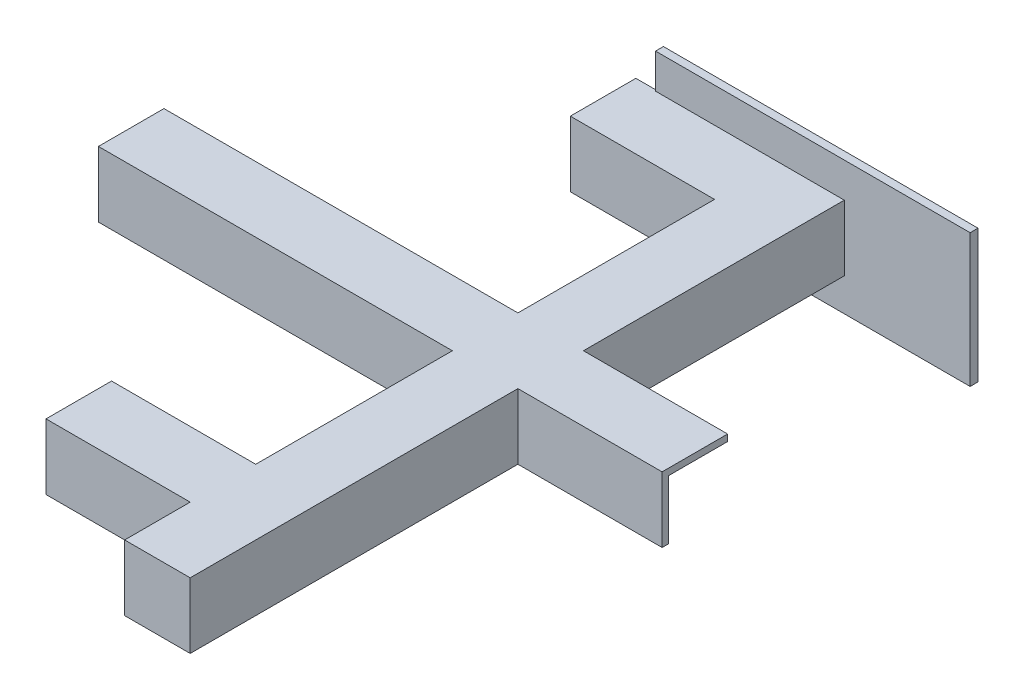
from build123d import *

# Parameters (mm, degrees)
BOSS_EXTRUDE1_START = 5
SKETCH1_W           = 50
SKETCH1_H           = 50
BOSS_EXTRUDE1_DEPTH = 500
BOSS_EXTRUDE2_DEPTH = 110
BOSS_EXTRUDE3_DEPTH = 110
BOSS_EXTRUDE5_START = 110
BOSS_EXTRUDE5_DEPTH = 160
SKETCH1_3_W         = 240
SKETCH1_3_H         = 101.6
SKETCH1_3_W_2       = 50
SKETCH1_3_H_2       = 50
BOSS_EXTRUDE6_DEPTH = 6


with BuildPart() as part:
    # Sketch1 → Boss-Extrude1 (new body)
    with BuildSketch(Plane.XY.offset(40212.600196057).offset(BOSS_EXTRUDE1_START)):
        with Locations((-21671.561141737, -1732.035725356)):
            Rectangle(SKETCH1_W, SKETCH1_H)
    extrude(amount=BOSS_EXTRUDE1_DEPTH)

    # Sketch2 → Boss-Extrude2 (add)
    with BuildSketch(Plane(origin=(-21646.561141737, 0, 0), x_dir=(0, 0, -1), z_dir=(1, 0, 0))):
        Polygon((-40467.600196057, -1707.035725356), (-40467.600196057, -1757.035725356), (-40462.600196057, -1757.035725356), (-40462.600196057, -1712.035725356), (-40417.600196057, -1712.035725356), (-40417.600196057, -1707.035725356), align=None)
    extrude(amount=BOSS_EXTRUDE2_DEPTH)

    # Sketch3 → Boss-Extrude3 (add)
    with BuildSketch(Plane.ZY.offset(21696.561141737)):
        Polygon((40667.600196057, -1707.035725356), (40617.600196057, -1707.035725356), (40617.600196057, -1712.035725356), (40662.600196057, -1712.035725356), (40662.600196057, -1757.035725356), (40667.600196057, -1757.035725356), align=None)
        Polygon((40467.600196057, -1757.035725356), (40467.600196057, -1707.035725356), (40417.600196057, -1707.035725356), (40417.600196057, -1712.035725356), (40462.600196057, -1712.035725356), (40462.600196057, -1757.035725356), align=None)
        Polygon((40267.600196057, -1757.035725356), (40267.600196057, -1707.035725356), (40217.600196057, -1707.035725356), (40217.600196057, -1712.035725356), (40262.600196057, -1712.035725356), (40262.600196057, -1757.035725356), align=None)
    extrude(amount=BOSS_EXTRUDE3_DEPTH)

    # Sketch3_3 → Boss-Extrude5 (add)
    with BuildSketch(Plane.ZY.offset(21696.561141737).offset(BOSS_EXTRUDE5_START)):
        Polygon((40467.600196057, -1757.035725356), (40467.600196057, -1707.035725356), (40417.600196057, -1707.035725356), (40417.600196057, -1712.035725356), (40462.600196057, -1712.035725356), (40462.600196057, -1757.035725356), align=None)
    extrude(amount=BOSS_EXTRUDE5_DEPTH)

    # Sketch1_3 → Boss-Extrude6 (add)
    with BuildSketch(Plane.XY.offset(40212.600196057)):
        with Locations((-21670.561141737, -1731.342871453)):
            Rectangle(SKETCH1_3_W, SKETCH1_3_H)
        with Locations((-21671.561141737, -1732.035725356)):
            Rectangle(SKETCH1_3_W_2, SKETCH1_3_H_2, mode=Mode.SUBTRACT)
    extrude(amount=BOSS_EXTRUDE6_DEPTH)


solid = part.part
